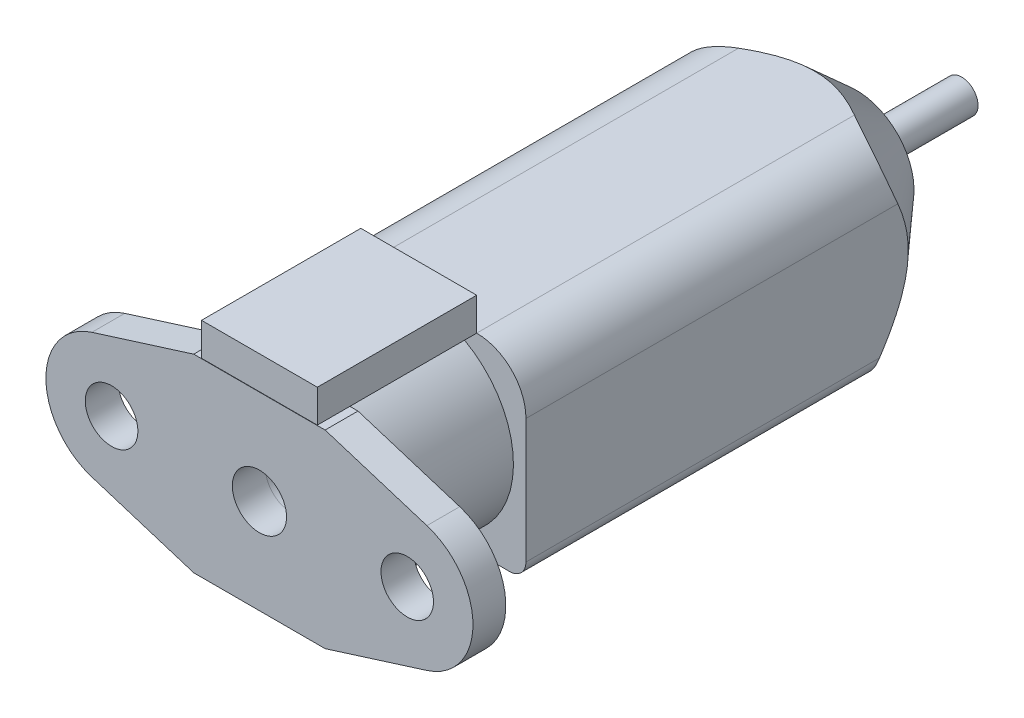
from build123d import *

# Parameters (mm, degrees)
CROQUIS1_R               = 1.598160281
CROQUIS1_R_2             = 1.600993429
CROQUIS1_R_3             = 1.650918845
SALIENTE_EXTRUIR7_DEPTH  = 2
CROQUIS2_R               = 5.764999893
CROQUIS2_R_2             = 1.651186543
SALIENTE_EXTRUIR8_DEPTH  = 7.7
SALIENTE_EXTRUIR9_DEPTH  = 26.65
CROQUIS6_R               = 0.999415005
SALIENTE_EXTRUIR10_DEPTH = 6.4
CROQUIS7_W               = 7.053736916
CROQUIS7_H               = 9.7
SALIENTE_EXTRUIR11_DEPTH = 2


with BuildPart() as part:
    # Croquis1 → Saliente-Extruir7 (new body)
    with BuildSketch(Plane.XY):
        with BuildLine():
            Line((4.00000019, 5.763000809), (10.195969576, 3.8191034))
            ThreePointArc((10.195969576, 3.8191034), (12.999977706, 0.001566069), (10.197782, -3.817301838))
            Line((10.197782, -3.817301838), (4.00000019, -5.764999893))
            Line((4.00000019, -5.764999893), (-4.00000019, -5.764999893))
            Line((-4.00000019, -5.764999893), (-10.199065979, -3.817665654))
            ThreePointArc((-10.199065979, -3.817665654), (-13.000622723, -0.001109837), (-10.199143851, 3.815503142))
            Line((-10.199143851, 3.815503142), (-4.00000019, 5.763000809))
            Line((-4.00000019, 5.763000809), (4.00000019, 5.763000809))
        make_face()
        with Locations((8.997973452, 0.000616233)):
            Circle(CROQUIS1_R, mode=Mode.SUBTRACT)
        with Locations((-9.000145119, -0.001069025)):
            Circle(CROQUIS1_R_2, mode=Mode.SUBTRACT)
        Circle(CROQUIS1_R_3, mode=Mode.SUBTRACT)
    extrude(amount=-SALIENTE_EXTRUIR7_DEPTH)

    # Croquis2 → Saliente-Extruir8 (add)
    with BuildSketch(Plane(origin=(0, 0, -2), x_dir=(-1, 0, 0), z_dir=(0, 0, -1))):
        with Locations(Location((0, 0, 0), (0, 0, 91.508919394))):
            Circle(CROQUIS2_R)
        with Locations(Location((0, 0, 0), (0, 0, 180))):
            Circle(CROQUIS2_R_2, mode=Mode.SUBTRACT)
    extrude(amount=SALIENTE_EXTRUIR8_DEPTH)

    # Croquis3 → Saliente-Extruir9 (add)
    with BuildSketch(Plane(origin=(0, 0, -9.7), x_dir=(-1, 0, 0), z_dir=(0, 0, -1))):
        with BuildLine():
            Line((3.526868458, 5.783774708), (-3.526868458, 5.783774708))
            ThreePointArc((-3.526868458, 5.783774708), (-5.648188802, 4.905095052), (-6.526868458, 2.783774708))
            Line((-6.526868458, 2.783774708), (-6.526868458, -4.783774708))
            ThreePointArc((-6.526868458, -4.783774708), (-6.233975239, -5.490881489), (-5.526868458, -5.783774708))
            Line((-5.526868458, -5.783774708), (5.526868458, -5.783774708))
            ThreePointArc((5.526868458, -5.783774708), (6.233975239, -5.490881489), (6.526868458, -4.783774708))
            Line((6.526868458, -4.783774708), (6.526868458, 2.783774708))
            ThreePointArc((6.526868458, 2.783774708), (5.648188802, 4.905095052), (3.526868458, 5.783774708))
        make_face()
    extrude(amount=SALIENTE_EXTRUIR9_DEPTH)

    # Croquis5 → Cortar-Revolución1 (revolve, cut)
    with BuildSketch(Plane(origin=(0, 0, 0), x_dir=(1, 0, 0), z_dir=(0, 1, 0)), mode=Mode.PRIVATE) as cortar_revoluci_n1_sk:
        Polygon((-3.5, 36.35), (-8.472559386, 30.803521887), (-8.472559386, 36.35), align=None)
    revolve(cortar_revoluci_n1_sk.sketch.rotate(Axis((0, 0, -39.9199001), (0, 0, 1)), 203.098732749), axis=Axis((0, 0, -39.9199001), (0, 0, 1)), mode=Mode.SUBTRACT)

    # Croquis6 → Saliente-Extruir10 (add)
    with BuildSketch(Plane(origin=(0, 0, -36.35), x_dir=(-1, 0, 0), z_dir=(0, 0, -1))):
        Circle(CROQUIS6_R)
    extrude(amount=SALIENTE_EXTRUIR10_DEPTH)


with BuildPart() as body_2:
    # Croquis7 → Saliente-Extruir11 (new body)
    with BuildSketch(Plane(origin=(0, 5.783774708, 0), x_dir=(1, 0, 0), z_dir=(0, 1, 0))):
        with Locations((0, 4.85)):
            Rectangle(CROQUIS7_W, CROQUIS7_H)
    extrude(amount=SALIENTE_EXTRUIR11_DEPTH)


solid = Compound([part.part, body_2.part])
